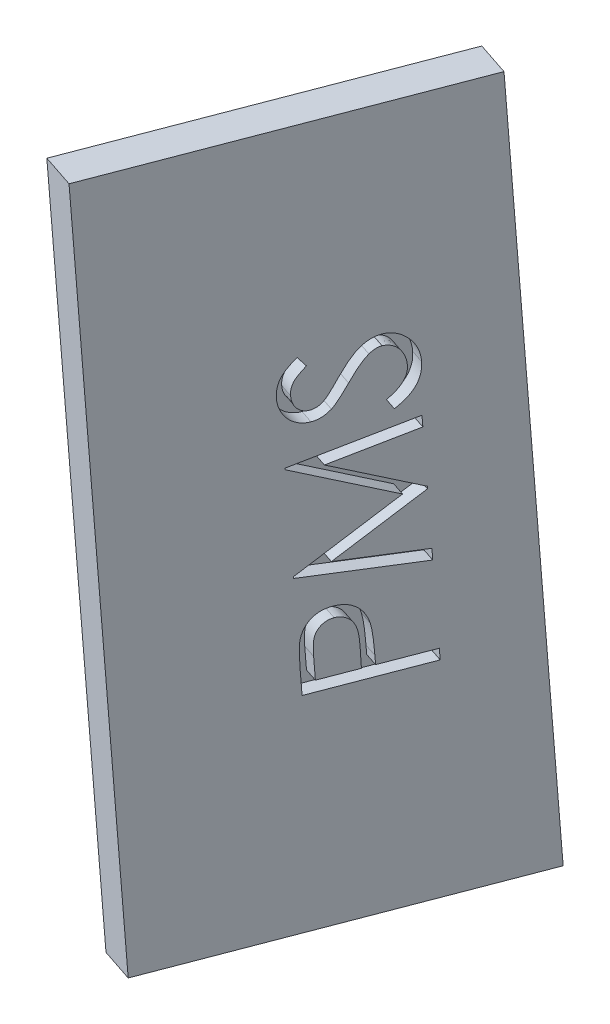
from build123d import *

# Parameters (mm, degrees)
SKETCH1_W           = 77.7
SKETCH1_H           = 40
BOSS_EXTRUDE1_DEPTH = 5
CUT_EXTRUDE2_DEPTH  = 2


with BuildPart() as part:
    # Sketch1 → Boss-Extrude1 (new body)
    with BuildSketch(Plane(origin=(318.504003389, -806.125521122, -1231.462820821), x_dir=(0.116479661, -0.992878889, 0.024979982), z_dir=(0.916321446, 0.117132497, 0.382929478))):
        with Locations((-93.510261675, 236.202444731)):
            Rectangle(SKETCH1_W, SKETCH1_H)
    extrude(amount=BOSS_EXTRUDE1_DEPTH)

    # Sketch3 → Cut-Extrude2 (cut)
    with BuildSketch(Plane(origin=(-246.614045293, -31.524438213, -103.059671981), x_dir=(0.383128563, 0.021713803, -0.923439773), z_dir=(0.916321446, 0.117132497, 0.382929478))):
        with BuildLine():
            Line((1475.496909513, -729.249890134), (1475.496909513, -726.759245102))
            add(Edge.make_bspline(
                [(1475.496909513, -726.759245102), (1475.497097823, -726.587936957), (1475.497458631, -726.259702943), (1475.508397852, -725.789022598), (1475.523008992, -725.361541572), (1475.54326329, -724.978181618), (1475.567199489, -724.637763205), (1475.600771175, -724.341826718), (1475.635824247, -724.088046042), (1475.671461922, -723.935985497), (1475.687714802, -723.866636929)],
                knots=[0, 0, 0, 0, 0.000513909, 0.000984672, 0.001412348, 0.001797041, 0.002136358, 0.002435846, 0.002690583, 0.002904164, 0.002904164, 0.002904164, 0.002904164], degree=3))
            add(Edge.make_bspline(
                [(1475.687714802, -723.866636929), (1475.71174396, -723.778849729), (1475.759236059, -723.605343925), (1475.854340823, -723.35532049), (1475.96717518, -723.117494807), (1476.095526785, -722.890805394), (1476.245713694, -722.67938104), (1476.407744611, -722.476173797), (1476.592090663, -722.288356867), (1476.792937517, -722.113386294), (1477.007737815, -721.951665847), (1477.240394204, -721.81579143), (1477.483960624, -721.696987072), (1477.741747345, -721.599715915), (1478.014004644, -721.527381041), (1478.298797691, -721.473679685), (1478.59644672, -721.439437718), (1478.79986669, -721.436169329), (1478.90341993, -721.434505519)],
                knots=[0, 0, 0, 0, 0.000272928, 0.000539425, 0.000801167, 0.00106213, 0.001319735, 0.001578393, 0.001841062, 0.00210791, 0.002377077, 0.00264628, 0.002914809, 0.003189345, 0.003471382, 0.003758783, 0.004058271, 0.004368814, 0.004368814, 0.004368814, 0.004368814], degree=3))
            add(Edge.make_bspline(
                [(1478.90341993, -721.434505519), (1479.007842149, -721.436034688), (1479.212151272, -721.439026612), (1479.511046818, -721.47493599), (1479.796682119, -721.523305543), (1480.068423839, -721.597680561), (1480.324658207, -721.695092004), (1480.569300963, -721.809363167), (1480.798190058, -721.94718912), (1481.012156456, -722.105557502), (1481.211400995, -722.28173043), (1481.394479821, -722.47496252), (1481.560321277, -722.684473667), (1481.709297153, -722.909598033), (1481.837952796, -723.152530342), (1481.953186445, -723.409586156), (1482.049964293, -723.682999798), (1482.100873373, -723.872202635), (1482.12675727, -723.968399749)],
                knots=[0, 0, 0, 0, 0.000313086, 0.000612574, 0.000902017, 0.001181599, 0.001456135, 0.001723565, 0.001990583, 0.002256192, 0.00252113, 0.002787469, 0.003053674, 0.003321805, 0.003596116, 0.003877417, 0.00416629, 0.004465075, 0.004465075, 0.004465075, 0.004465075], degree=3))
            add(Edge.make_bspline(
                [(1482.12675727, -723.968399749), (1482.14366462, -724.047965553), (1482.18071806, -724.222338638), (1482.22236509, -724.509495652), (1482.256520205, -724.844001396), (1482.288394031, -725.224717732), (1482.305283174, -725.652532484), (1482.325113783, -726.126464448), (1482.334470764, -726.64811757), (1482.335062242, -727.011954358), (1482.335371052, -727.201913371)],
                knots=[0, 0, 0, 0, 0.000243979, 0.000534694, 0.000869865, 0.001252695, 0.001680583, 0.002154115, 0.002675749, 0.003245626, 0.003245626, 0.003245626, 0.003245626], degree=3))
            Line((1482.335371052, -727.201913371), (1482.335371052, -728.110146544))
            Line((1482.335371052, -728.110146544), (1488.196909513, -728.110146544))
            Line((1488.196909513, -728.110146544), (1488.196909513, -729.249890134))
            Line((1488.196909513, -729.249890134), (1475.496909513, -729.249890134))
        make_face()
        with BuildLine():
            Line((1476.799473616, -728.110146544), (1481.032806949, -728.110146544))
            Line((1481.032806949, -728.110146544), (1481.060791725, -725.886628916))
            add(Edge.make_bspline(
                [(1481.060791725, -725.886628916), (1481.060851507, -725.778061569), (1481.060966916, -725.568474544), (1481.046457136, -725.265730402), (1481.02993044, -724.984810815), (1481.004934772, -724.726772159), (1480.972169409, -724.490709026), (1480.931422402, -724.278660425), (1480.887123925, -724.087454825), (1480.813112159, -723.867509822), (1480.699311474, -723.620284393), (1480.53364919, -723.350209482), (1480.319041612, -723.123096569), (1480.078421145, -722.926924526), (1479.811461682, -722.768185245), (1479.524328549, -722.656201015), (1479.221275593, -722.587245748), (1479.014029136, -722.578633896), (1478.908508071, -722.574249108)],
                knots=[0, 0, 0, 0, 0.000325651, 0.000628662, 0.000909076, 0.001169816, 0.001406195, 0.001623739, 0.00181749, 0.001994481, 0.002318937, 0.002632302, 0.002940177, 0.003251283, 0.003561503, 0.003867638, 0.004172555, 0.00448885, 0.00448885, 0.00448885, 0.00448885], degree=3))
            add(Edge.make_bspline(
                [(1478.908508071, -722.574249108), (1478.806405565, -722.578830757), (1478.603438419, -722.587938507), (1478.305971159, -722.655631969), (1478.022092932, -722.769387748), (1477.757283332, -722.927063305), (1477.517192327, -723.118474556), (1477.308270981, -723.340772197), (1477.141442262, -723.594524934), (1477.029616483, -723.82860583), (1476.964146439, -724.038222392), (1476.91685981, -724.219396274), (1476.88425242, -724.425007441), (1476.853051215, -724.653102275), (1476.827865616, -724.903391178), (1476.810375775, -725.177464924), (1476.800247298, -725.474410823), (1476.799737754, -725.680551069), (1476.799473616, -725.787410166)],
                knots=[0, 0, 0, 0, 0.000306146, 0.00060858, 0.000909985, 0.001220206, 0.001529716, 0.001828533, 0.002131234, 0.002437391, 0.002603127, 0.00278947, 0.002998595, 0.003227067, 0.003480211, 0.003753009, 0.004050839, 0.004371402, 0.004371402, 0.004371402, 0.004371402], degree=3))
            Line((1476.799473616, -725.787410166), (1476.799473616, -728.110146544))
        make_face(mode=Mode.SUBTRACT)
        Polygon((1488.196909513, -719.480659365), (1475.496909513, -717.804116897), (1475.496909513, -717.641296384), (1485.917422334, -712.397967057), (1475.496909513, -707.167358083), (1475.496909513, -707.001993499), (1488.196909513, -705.315274749), (1488.196909513, -706.46010648), (1479.058608231, -707.676172185), (1488.196909513, -712.260587249), (1488.196909513, -712.517538371), (1479.038255667, -717.119761929), (1488.196909513, -718.333283563), align=None)
        with BuildLine():
            Line((1485.746969609, -704.012710647), (1485.10331977, -702.93911289))
            add(Edge.make_bspline(
                [(1485.10331977, -702.93911289), (1485.270467681, -702.839261001), (1485.590716628, -702.647948634), (1486.023452946, -702.328810845), (1486.391252772, -701.998128567), (1486.691976462, -701.653452986), (1486.928736709, -701.296887974), (1487.096384807, -700.926105836), (1487.200945632, -700.542356066), (1487.213645946, -700.281193914), (1487.219986436, -700.150811608)],
                knots=[0, 0, 0, 0, 0.000583841, 0.001118616, 0.00161028, 0.002064766, 0.002487434, 0.002889373, 0.003281209, 0.003671854, 0.003671854, 0.003671854, 0.003671854], degree=3))
            add(Edge.make_bspline(
                [(1487.219986436, -700.150811608), (1487.216811416, -700.039484686), (1487.210516931, -699.8187788), (1487.152478653, -699.493227366), (1487.057528148, -699.178633814), (1486.92881246, -698.878125402), (1486.770592895, -698.599663635), (1486.584022335, -698.351564041), (1486.368446731, -698.142070237), (1486.131852142, -697.96839734), (1485.878143392, -697.834010515), (1485.616732565, -697.732439646), (1485.344032906, -697.675554489), (1485.160381872, -697.667018377), (1485.067702783, -697.662710647)],
                knots=[0, 0, 0, 0, 0.000333749, 0.000661658, 0.00098843, 0.001317806, 0.001640301, 0.001947123, 0.002245767, 0.002538865, 0.00282455, 0.003104744, 0.003377672, 0.003655722, 0.003655722, 0.003655722, 0.003655722], degree=3))
            add(Edge.make_bspline(
                [(1485.067702783, -697.662710647), (1484.961927835, -697.66794539), (1484.747722033, -697.678546315), (1484.431145805, -697.771972973), (1484.116504169, -697.91463157), (1483.921841389, -698.048714618), (1483.821108231, -698.118099269)],
                knots=[0, 0, 0, 0, 0.000316704, 0.000641359, 0.000982872, 0.001349121, 0.001349121, 0.001349121, 0.001349121], degree=3))
            add(Edge.make_bspline(
                [(1483.821108231, -698.118099269), (1483.748357703, -698.174952876), (1483.595627069, -698.294309912), (1483.368475842, -698.499679253), (1483.133694769, -698.739439311), (1482.886129583, -699.010308588), (1482.627836527, -699.312741446), (1482.356800014, -699.646854899), (1482.0785587, -700.015500412), (1481.892190847, -700.274251453), (1481.796028103, -700.40776273)],
                knots=[0, 0, 0, 0, 0.00027693, 0.00058138, 0.000917785, 0.001283326, 0.001682064, 0.002110776, 0.002573803, 0.003067412, 0.003067412, 0.003067412, 0.003067412], degree=3))
            add(Edge.make_bspline(
                [(1481.796028103, -700.40776273), (1481.700855799, -700.541381231), (1481.518893602, -700.796849628), (1481.248839772, -701.154113627), (1481.001937731, -701.47358925), (1480.775863172, -701.753856539), (1480.570585435, -701.994792219), (1480.38807577, -702.198294881), (1480.223398278, -702.359180503), (1480.116568267, -702.448645038), (1480.068604225, -702.48881241)],
                knots=[0, 0, 0, 0, 0.000492118, 0.000940893, 0.001343419, 0.001703394, 0.002021005, 0.002292935, 0.002523226, 0.002710868, 0.002710868, 0.002710868, 0.002710868], degree=3))
            add(Edge.make_bspline(
                [(1480.068604225, -702.48881241), (1479.99384818, -702.544946235), (1479.846830386, -702.655340936), (1479.617104495, -702.80122025), (1479.382390041, -702.924240673), (1479.141836366, -703.023249114), (1478.897251374, -703.103313488), (1478.646798818, -703.158978768), (1478.392178919, -703.193289669), (1478.22086729, -703.196833887), (1478.135110635, -703.198608083)],
                knots=[0, 0, 0, 0, 0.000280379, 0.000551403, 0.000815399, 0.001074307, 0.001330956, 0.00158648, 0.001843028, 0.00210018, 0.00210018, 0.00210018, 0.00210018], degree=3))
            add(Edge.make_bspline(
                [(1478.135110635, -703.198608083), (1478.00074519, -703.193872249), (1477.734886268, -703.184501808), (1477.346521066, -703.105248872), (1476.975716148, -702.980172915), (1476.626228004, -702.804888646), (1476.306837613, -702.579143541), (1476.014670156, -702.31676435), (1475.765700978, -702.007149758), (1475.551561327, -701.664383389), (1475.382218705, -701.291169944), (1475.259495517, -700.898257342), (1475.186599484, -700.488469967), (1475.176429032, -700.210463431), (1475.171268488, -700.069401352)],
                knots=[0, 0, 0, 0, 0.000402767, 0.000796926, 0.001183901, 0.001574148, 0.001965141, 0.002354126, 0.002748285, 0.003152792, 0.003563783, 0.00397416, 0.004384892, 0.004807973, 0.004807973, 0.004807973, 0.004807973], degree=3))
            add(Edge.make_bspline(
                [(1475.171268488, -700.069401352), (1475.176360228, -699.919719956), (1475.186486074, -699.622051432), (1475.276718781, -699.184896678), (1475.420328218, -698.762285625), (1475.588819711, -698.423829753), (1475.756031299, -698.158376529), (1475.908665738, -697.95613775), (1476.084021136, -697.750085023), (1476.285794254, -697.542432798), (1476.509949428, -697.331131116), (1476.758384147, -697.117153284), (1477.028859611, -696.898496834), (1477.221996772, -696.757876331), (1477.321008071, -696.68578757)],
                knots=[0, 0, 0, 0, 0.00044863, 0.000892182, 0.001333063, 0.001784748, 0.002022602, 0.002273448, 0.002544149, 0.002833827, 0.003141576, 0.003468021, 0.003817263, 0.004184633, 0.004184633, 0.004184633, 0.004184633], degree=3))
            Line((1477.321008071, -696.68578757), (1478.102037718, -697.716136128))
            add(Edge.make_bspline(
                [(1478.102037718, -697.716136128), (1478.021882689, -697.778346832), (1477.867522843, -697.898150104), (1477.651425772, -698.080108865), (1477.4537626, -698.251349499), (1477.282528282, -698.421353997), (1477.12490012, -698.577018457), (1476.992339941, -698.730783439), (1476.880659475, -698.87671513), (1476.761258194, -699.060220198), (1476.646479879, -699.292679084), (1476.545660621, -699.582052986), (1476.485849257, -699.885482575), (1476.477871341, -700.092037997), (1476.47383259, -700.196604878)],
                knots=[0, 0, 0, 0, 0.000304354, 0.000586115, 0.000847462, 0.001088545, 0.001309821, 0.001511814, 0.001697025, 0.001860738, 0.002167928, 0.002472049, 0.002777898, 0.00309148, 0.00309148, 0.00309148, 0.00309148], degree=3))
            add(Edge.make_bspline(
                [(1476.47383259, -700.196604878), (1476.478157336, -700.327832362), (1476.4864972, -700.580892205), (1476.579977814, -700.939326087), (1476.722108788, -701.263798195), (1476.92706017, -701.541921865), (1477.171401695, -701.771564265), (1477.450055995, -701.939740192), (1477.757818827, -702.040289622), (1477.972401598, -702.052596697), (1478.081685154, -702.058864493)],
                knots=[0, 0, 0, 0, 0.000392785, 0.000757449, 0.001103592, 0.001449623, 0.001786259, 0.002103452, 0.002418835, 0.002746151, 0.002746151, 0.002746151, 0.002746151], degree=3))
            add(Edge.make_bspline(
                [(1478.081685154, -702.058864493), (1478.149710631, -702.057356514), (1478.286709206, -702.054319548), (1478.488149744, -702.015512042), (1478.688528152, -701.963041104), (1478.8871392, -701.882600641), (1479.088480304, -701.770580634), (1479.295395242, -701.623634378), (1479.509666262, -701.438519733), (1479.64903051, -701.296727384), (1479.722610635, -701.221865294)],
                knots=[0, 0, 0, 0, 0.00020378, 0.000410399, 0.000613447, 0.00082462, 0.001051213, 0.001303192, 0.001584654, 0.001899472, 0.001899472, 0.001899472, 0.001899472], degree=3))
            add(Edge.make_bspline(
                [(1479.722610635, -701.221865294), (1479.747419272, -701.194065457), (1479.806358913, -701.128019408), (1479.902850903, -701.007275334), (1480.021878105, -700.847825752), (1480.169152082, -700.653834337), (1480.339990531, -700.421724195), (1480.532209066, -700.151469806), (1480.752047732, -699.846083673), (1480.905745093, -699.629378435), (1480.98701368, -699.51479398)],
                knots=[0, 0, 0, 0, 0.000111766, 0.000265529, 0.000463461, 0.000708709, 0.000996201, 0.001328024, 0.001703617, 0.002125051, 0.002125051, 0.002125051, 0.002125051], degree=3))
            add(Edge.make_bspline(
                [(1480.98701368, -699.51479398), (1481.087312398, -699.376959478), (1481.281526966, -699.110062067), (1481.573320046, -698.730303248), (1481.858702374, -698.385978791), (1482.135832953, -698.075854323), (1482.402671605, -697.796951358), (1482.662221763, -697.5520814), (1482.912781333, -697.340133416), (1483.231829841, -697.108840101), (1483.627302146, -696.875302417), (1484.112048718, -696.675063047), (1484.598186361, -696.547674189), (1484.924507065, -696.531129891), (1485.085511276, -696.522967057)],
                knots=[0, 0, 0, 0, 0.000511383, 0.000990223, 0.001436481, 0.001852691, 0.002237729, 0.002594081, 0.002922749, 0.003221458, 0.003775598, 0.004295766, 0.004791239, 0.005273789, 0.005273789, 0.005273789, 0.005273789], degree=3))
            add(Edge.make_bspline(
                [(1485.085511276, -696.522967057), (1485.199368709, -696.52535396), (1485.42487254, -696.530081414), (1485.756015644, -696.584332817), (1486.077553857, -696.664001323), (1486.385194705, -696.783112363), (1486.683874372, -696.930862456), (1486.96796631, -697.115655279), (1487.242989816, -697.330973895), (1487.501234553, -697.57784329), (1487.738594738, -697.847836839), (1487.948865033, -698.134228555), (1488.12822728, -698.434028766), (1488.271071721, -698.750484106), (1488.383544679, -699.080195006), (1488.464808779, -699.424248731), (1488.514739342, -699.782993801), (1488.519917739, -700.026836927), (1488.522550539, -700.150811608)],
                knots=[0, 0, 0, 0, 0.000341247, 0.000675867, 0.001004131, 0.001333458, 0.001663404, 0.002002138, 0.002348216, 0.002709912, 0.003072253, 0.003425393, 0.003774441, 0.004118267, 0.004465018, 0.004817984, 0.005177419, 0.005549167, 0.005549167, 0.005549167, 0.005549167], degree=3))
            add(Edge.make_bspline(
                [(1488.522550539, -700.150811608), (1488.52069568, -700.246734138), (1488.517009322, -700.437371153), (1488.484420107, -700.719345562), (1488.438311462, -700.995623486), (1488.365108453, -701.262738219), (1488.276291829, -701.52413092), (1488.166933356, -701.778665897), (1488.035877163, -702.026462112), (1487.886044232, -702.268925053), (1487.711628191, -702.505373076), (1487.508664222, -702.733844809), (1487.282327849, -702.960350705), (1487.029122559, -703.18328401), (1486.746263972, -703.39778102), (1486.437965382, -703.608991121), (1486.103309977, -703.815884991), (1485.867968295, -703.945876665), (1485.746969609, -704.012710647)],
                knots=[0, 0, 0, 0, 0.00028766, 0.000571697, 0.000850676, 0.001127139, 0.001401486, 0.001678416, 0.001957221, 0.002241725, 0.002532773, 0.002837436, 0.003157645, 0.003492942, 0.003848621, 0.004221915, 0.004613751, 0.005028396, 0.005028396, 0.005028396, 0.005028396], degree=3))
        make_face()
    extrude(amount=-CUT_EXTRUDE2_DEPTH, mode=Mode.SUBTRACT)


solid = part.part
